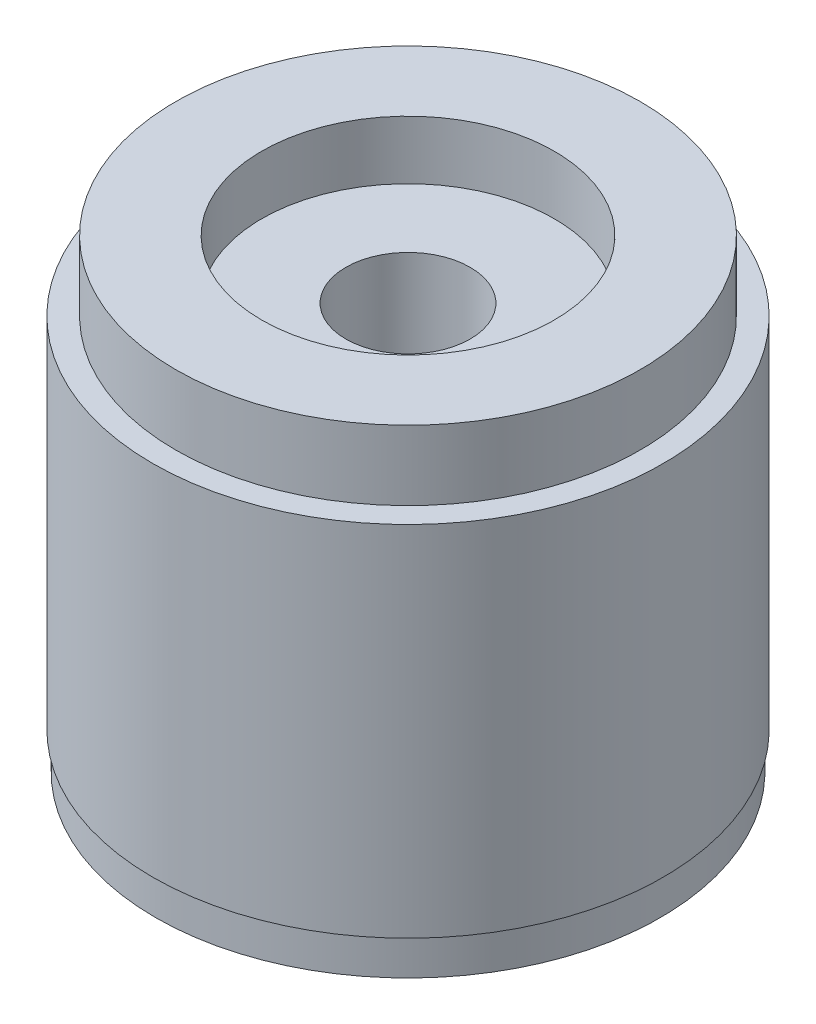
from build123d import *

# Parameters (mm, degrees)
SKETCH1_R           = 34.91
BOSS_EXTRUDE1_DEPTH = 63.5
SKETCH2_OUTSIDE_W   = 95.3
SKETCH2_OUTSIDE_H   = 95.3
SKETCH2_OUTSIDE_R   = 34.5
CUT_EXTRUDE1_DEPTH  = 5
SKETCH3_OUTSIDE_W   = 95.3
SKETCH3_OUTSIDE_H   = 95.3
SKETCH3_OUTSIDE_R   = 31.75
CUT_EXTRUDE2_DEPTH  = 9.52
SKETCH4_R           = 20
CUT_EXTRUDE3_DEPTH  = 8
SKETCH5_R           = 8.5
CUT_EXTRUDE4_DEPTH  = 64.5
SKETCH6_R           = 14.5
CUT_EXTRUDE5_DEPTH  = 5


with BuildPart() as part:
    # Sketch1 → Boss-Extrude1 (new body)
    with BuildSketch(Plane(origin=(0, 0, 0), x_dir=(1, 0, 0), z_dir=(0, 1, 0))):
        Circle(SKETCH1_R)
    extrude(amount=BOSS_EXTRUDE1_DEPTH)

    # Sketch2 outside → Cut-Extrude1 (cut)
    with BuildSketch(Plane.XZ):
        Rectangle(SKETCH2_OUTSIDE_W, SKETCH2_OUTSIDE_H)
        Circle(SKETCH2_OUTSIDE_R, mode=Mode.SUBTRACT)
    extrude(amount=-CUT_EXTRUDE1_DEPTH, mode=Mode.SUBTRACT)

    # Sketch3 outside → Cut-Extrude2 (cut)
    with BuildSketch(Plane(origin=(0, 63.5, 0), x_dir=(1, 0, 0), z_dir=(0, 1, 0))):
        Rectangle(SKETCH3_OUTSIDE_W, SKETCH3_OUTSIDE_H)
        Circle(SKETCH3_OUTSIDE_R, mode=Mode.SUBTRACT)
    extrude(amount=-CUT_EXTRUDE2_DEPTH, mode=Mode.SUBTRACT)

    # Sketch4 → Cut-Extrude3 (cut)
    with BuildSketch(Plane(origin=(0, 63.5, 0), x_dir=(1, 0, 0), z_dir=(0, 1, 0))):
        Circle(SKETCH4_R)
    extrude(amount=-CUT_EXTRUDE3_DEPTH, mode=Mode.SUBTRACT)

    # Sketch5 → Cut-Extrude4 (cut, through all)
    with BuildSketch(Plane.XZ):
        Circle(SKETCH5_R)
    extrude(amount=-CUT_EXTRUDE4_DEPTH, mode=Mode.SUBTRACT)

    # Sketch6 → Cut-Extrude5 (cut)
    with BuildSketch(Plane.XZ):
        Circle(SKETCH6_R)
    extrude(amount=-CUT_EXTRUDE5_DEPTH, mode=Mode.SUBTRACT)


solid = part.part
